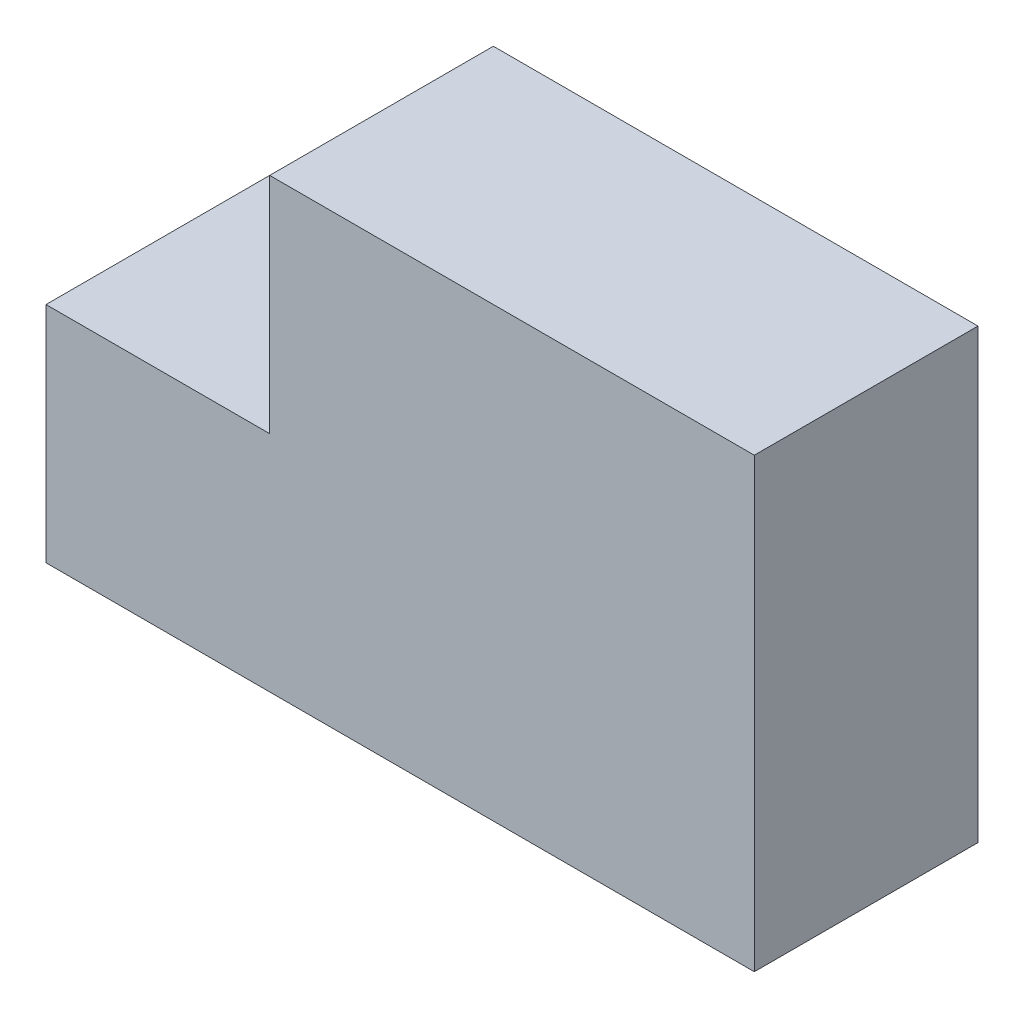
from build123d import *

# Parameters (mm, degrees)
RESSALTO_EXTRUS_O1_DEPTH = 6


with BuildPart() as part:
    # Esboço1 → Ressalto-extrusão1 (new body)
    with BuildSketch(Plane.XY):
        Polygon((0, 6), (0, 0), (19, 0), (19, 12), (6, 12), (6, 6), align=None)
    extrude(amount=RESSALTO_EXTRUS_O1_DEPTH)


solid = part.part
